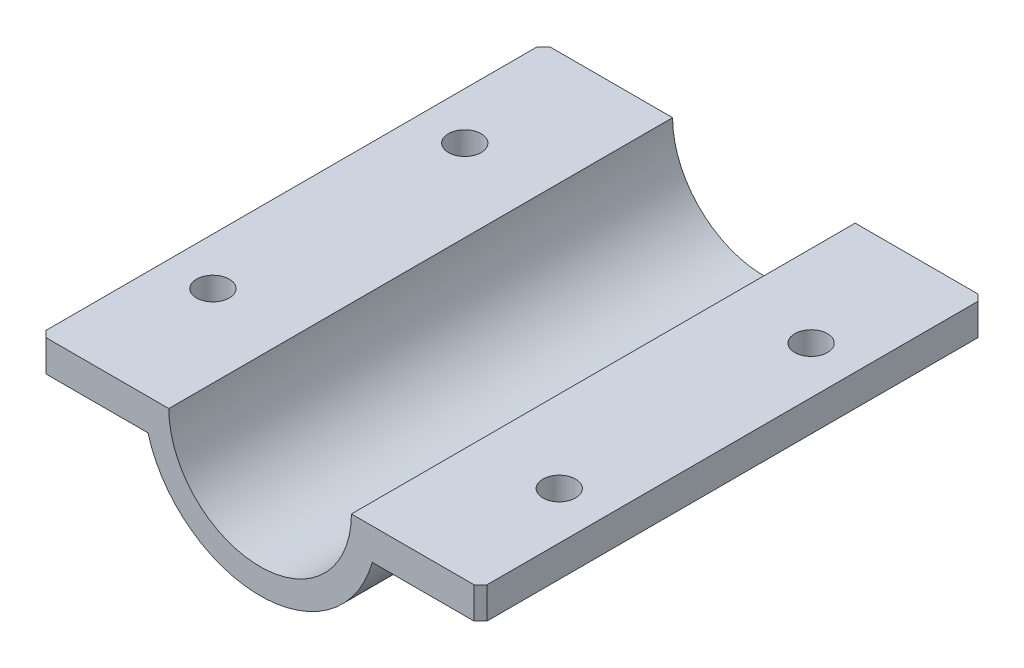
from build123d import *

# Parameters (mm, degrees)
EXTRUDE_1_DEPTH     = 40
SKETCH_2_R          = 2.6
CUT_EXTRUDE_1_DEPTH = 10
CHAMFER_1_SIZE      = 1


with BuildPart() as part:
    # 草图1 → 凸台-拉伸1 (new body, symmetric)
    with BuildSketch(Plane.XY):
        with BuildLine():
            Line((35, 0), (14.5, 0))
            ThreePointArc((14.5, 0), (0, -14.5), (-14.5, 0))
            Line((-14.5, 0), (-35, 0))
            Line((-35, 0), (-35, -5))
            Line((-35, -5), (-21.937410968, -5))
            Line((-21.937410968, -5), (-17.811513131, -5))
            ThreePointArc((-17.811513131, -5), (0, -18.5), (17.811513131, -5))
            Line((17.811513131, -5), (21.937410968, -5))
            Line((21.937410968, -5), (35, -5))
            Line((35, -5), (35, 0))
        make_face()
    extrude(amount=EXTRUDE_1_DEPTH, both=True)

    # 草图2 → 切除-拉伸1 (cut)
    with BuildSketch(Plane(origin=(0, -5, 0), x_dir=(-1, 0, 0), z_dir=(0, -1, 0))):
        with Locations((27.5, -20)):
            Circle(SKETCH_2_R)
        with Locations((27.5, 20)):
            Circle(SKETCH_2_R)
        with Locations((-27.5, -20)):
            Circle(SKETCH_2_R)
        with Locations((-27.5, 20)):
            Circle(SKETCH_2_R)
    extrude(amount=-CUT_EXTRUDE_1_DEPTH, mode=Mode.SUBTRACT)

    # 倒角1
    chamfer_1_edges = [part.edges().sort_by_distance(p)[0] for p in [
        (-35, -2.5, -40),
        (35, -2.5, -40),
        (-35, -2.5, 40),
        (35, -2.5, 40),
    ]]
    chamfer(chamfer_1_edges, length=CHAMFER_1_SIZE)


solid = part.part
